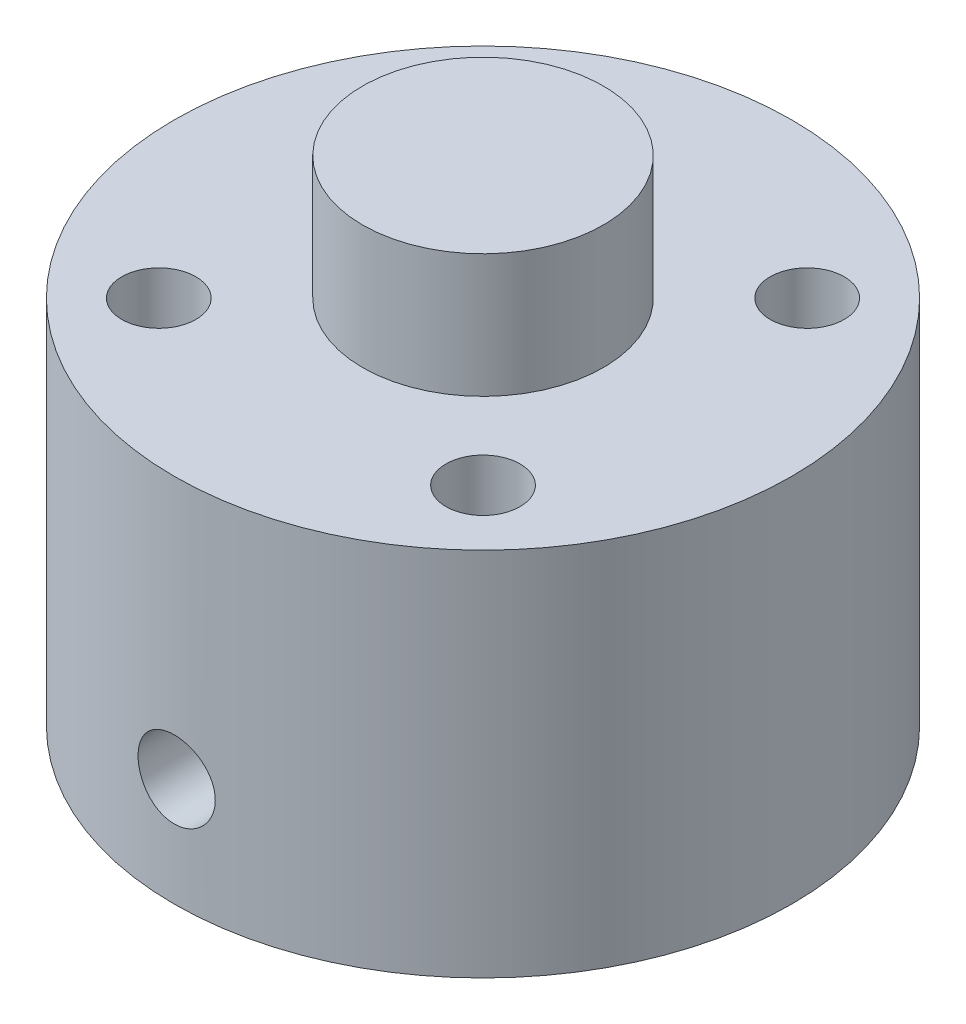
from build123d import *

# Parameters (mm, degrees)
SKIZZE1_R                       = 10
AUFSATZ_LINEAR_AUSTRAGEN1_DEPTH = 12
SKIZZE2_R                       = 3.9
AUFSATZ_LINEAR_AUSTRAGEN2_DEPTH = 4
SKIZZE3_R                       = 2.2
SCHNITT_LINEAR_AUSTRAGEN1_DEPTH = 8
SCHNITT_LINEAR_AUSTRAGEN2_REACH = 22
SKIZZE4_R                       = 1.25
SKIZZE5_R                       = 1.2
SCHNITT_LINEAR_AUSTRAGEN3_DEPTH = 9


with BuildPart() as part:
    # Skizze1 → Aufsatz-Linear austragen1 (new body)
    with BuildSketch(Plane(origin=(0, 0, 0), x_dir=(1, 0, 0), z_dir=(0, 1, 0))):
        Circle(SKIZZE1_R)
    extrude(amount=AUFSATZ_LINEAR_AUSTRAGEN1_DEPTH)

    # Skizze2 → Aufsatz-Linear austragen2 (add)
    with BuildSketch(Plane(origin=(0, 12, 0), x_dir=(1, 0, 0), z_dir=(0, 1, 0))):
        Circle(SKIZZE2_R)
    extrude(amount=AUFSATZ_LINEAR_AUSTRAGEN2_DEPTH)

    # Skizze3 → Schnitt-Linear austragen1 (cut)
    with BuildSketch(Plane.XZ):
        Circle(SKIZZE3_R)
    extrude(amount=-SCHNITT_LINEAR_AUSTRAGEN1_DEPTH, mode=Mode.SUBTRACT)

    # Skizze4 → Schnitt-Linear austragen2 (cut, up to next)
    with BuildSketch(Plane.XY.offset(10), mode=Mode.PRIVATE) as schnitt_linear_austragen2_sk1:
        with Locations((0, 3.5)):
            Circle(SKIZZE4_R)
    schnitt_linear_austragen2_tool1 = extrude(schnitt_linear_austragen2_sk1.sketch, amount=-SCHNITT_LINEAR_AUSTRAGEN2_REACH, mode=Mode.PRIVATE) & part.part
    add(schnitt_linear_austragen2_tool1.solids().sort_by_distance((0, 3.5, 10))[0], mode=Mode.SUBTRACT)

    # Skizze5 → Schnitt-Linear austragen3 (cut)
    with BuildSketch(Plane(origin=(0, 12, 0), x_dir=(1, 0, 0), z_dir=(0, 1, 0))):
        with Locations((-5.25, 5.25)):
            Circle(SKIZZE5_R)
        with Locations((5.25, 5.25)):
            Circle(SKIZZE5_R)
        with Locations((5.25, -5.25)):
            Circle(SKIZZE5_R)
        with Locations((-5.25, -5.25)):
            Circle(SKIZZE5_R)
    extrude(amount=-SCHNITT_LINEAR_AUSTRAGEN3_DEPTH, mode=Mode.SUBTRACT)


solid = part.part
